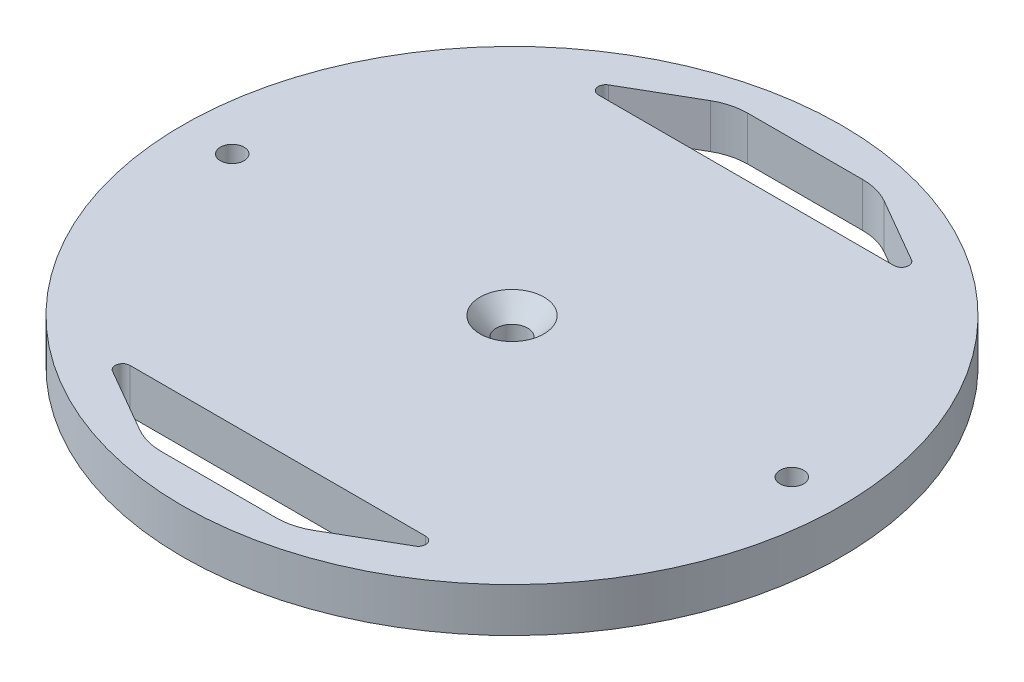
from build123d import *

# Parameters (mm, degrees)
SKETCH2_R                                        = 71.0565
BOSS_EXTRUDE1_DEPTH                              = 9.525
TAP_DRILL_FOR_1_4_20_TAP1_D                      = 5.1054
CSK_FOR_1_4_FLAT_HEAD_MACHINE_SCREW1_D           = 6.7564
CSK_FOR_1_4_FLAT_HEAD_MACHINE_SCREW1_CSINK_D     = 13.7668
CSK_FOR_1_4_FLAT_HEAD_MACHINE_SCREW1_CSINK_ANGLE = 82
CUT_EXTRUDE1_START                               = -10.525
CUT_EXTRUDE1_DEPTH                               = 11.525
FILLET1_R                                        = 12.7
FILLET2_R                                        = 1.5875
FILLET1_OF_MIRROR1_R                             = 12.7
FILLET2_OF_MIRROR1_R                             = 1.5875


with BuildPart() as part:
    # Sketch2 → Boss-Extrude1 (new body)
    with BuildSketch(Plane(origin=(0, 0, 0), x_dir=(1, 0, 0), z_dir=(0, 1, 0))):
        Circle(SKETCH2_R)
    extrude(amount=BOSS_EXTRUDE1_DEPTH)

    # Tap Drill for 1/4-20 Tap1 (through all)
    with Locations(Plane(origin=(0, 9.525, 0), x_dir=(1, 0, 0), z_dir=(0, 1, 0))):
        with Locations((-60.325, 0), (60.325, 0)):
            Hole(TAP_DRILL_FOR_1_4_20_TAP1_D / 2)

    # CSK for 1/4 Flat Head Machine Screw1 (through all)
    with Locations(Plane(origin=(0, 9.525, 0), x_dir=(1, 0, 0), z_dir=(0, 1, 0))):
        with Locations((0, 0)):
            CounterSinkHole(CSK_FOR_1_4_FLAT_HEAD_MACHINE_SCREW1_D / 2, CSK_FOR_1_4_FLAT_HEAD_MACHINE_SCREW1_CSINK_D / 2, counter_sink_angle=CSK_FOR_1_4_FLAT_HEAD_MACHINE_SCREW1_CSINK_ANGLE)

    # Sketch8 → Cut-Extrude1 (cut)
    with BuildSketch(Plane(origin=(0, 9.525, 0), x_dir=(1, 0, 0), z_dir=(0, 1, 0)).offset(CUT_EXTRUDE1_START)):
        Polygon((-37.8, 50.5), (-15.802954744, 63.2), (15.802954744, 63.2), (37.8, 50.5), align=None)
    cut_extrude1 = extrude(amount=CUT_EXTRUDE1_DEPTH, mode=Mode.SUBTRACT)

    # Fillet1
    fillet1_edges = [part.edges().sort_by_distance(p)[0] for p in [
        (-15.802954744, 4.7625, -63.2),
        (15.802954744, 4.7625, -63.2),
    ]]
    fillet(fillet1_edges, radius=FILLET1_R)

    # Fillet2
    fillet2_edges = [part.edges().sort_by_distance(p)[0] for p in [
        (37.8, 4.7625, -50.5),
        (-37.8, 4.7625, -50.5),
    ]]
    fillet(fillet2_edges, radius=FILLET2_R)

    # Mirror1: Cut-Extrude1 across plane
    add(cut_extrude1.mirror(Plane.XY), mode=Mode.SUBTRACT)

    # Fillet1 of Mirror1
    fillet1_of_mirror1_edges = [part.edges().sort_by_distance(p)[0] for p in [
        (-15.802954744, 4.7625, 63.2),
        (15.802954744, 4.7625, 63.2),
    ]]
    fillet(fillet1_of_mirror1_edges, radius=FILLET1_OF_MIRROR1_R)

    # Fillet2 of Mirror1
    fillet2_of_mirror1_edges = [part.edges().sort_by_distance(p)[0] for p in [
        (37.8, 4.7625, 50.5),
        (-37.8, 4.7625, 50.5),
    ]]
    fillet(fillet2_of_mirror1_edges, radius=FILLET2_OF_MIRROR1_R)


solid = part.part
